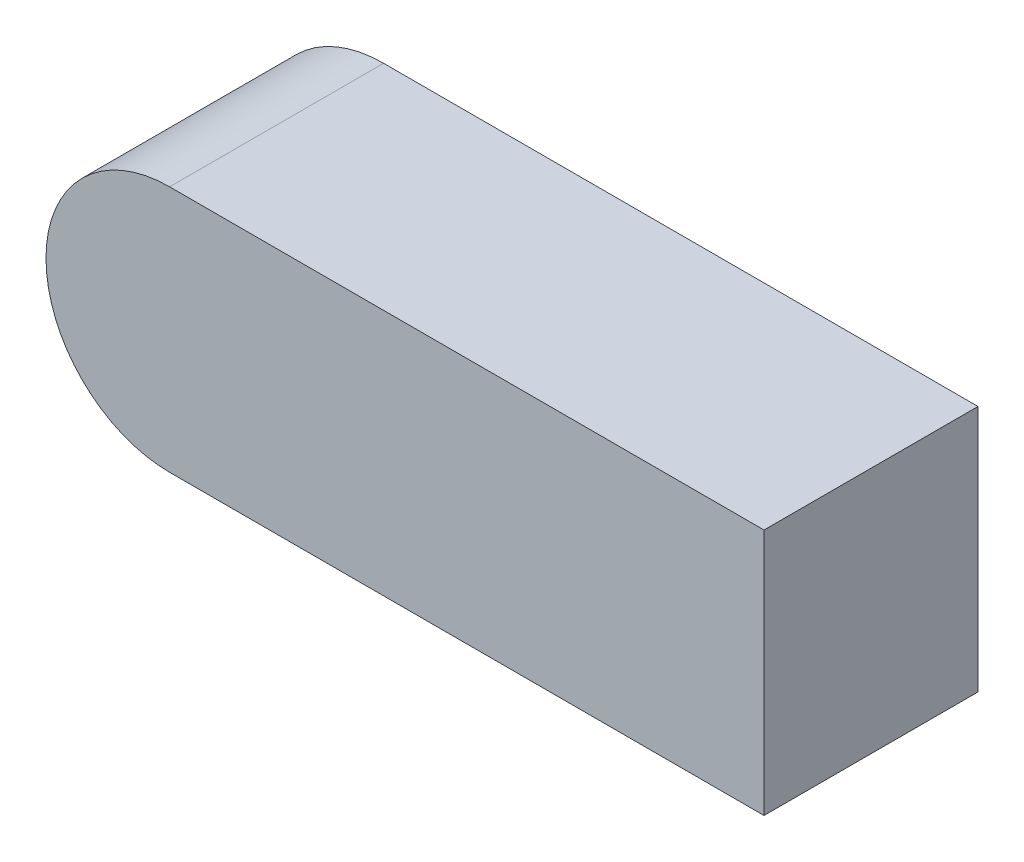
from build123d import *

# Parameters (mm, degrees)
SKETCH1_W           = 45
SKETCH1_H           = 52
BOSS_EXTRUDE1_DEPTH = 62.5
BOSS_EXTRUDE3_DEPTH = 45


with BuildPart() as part:
    # Sketch1 → Boss-Extrude1 (new body, symmetric)
    with BuildSketch(Plane(origin=(0, 0, 0), x_dir=(0, 0, -1), z_dir=(1, 0, 0))):
        Rectangle(SKETCH1_W, SKETCH1_H)
    extrude(amount=BOSS_EXTRUDE1_DEPTH, both=True)

    # Sketch3 → Boss-Extrude3 (add)
    with BuildSketch(Plane(origin=(0, 0, -22.5), x_dir=(-1, 0, 0), z_dir=(0, 0, -1))):
        with BuildLine():
            Line((62.5, -26), (62.5, 26))
            ThreePointArc((62.5, 26), (88.5, 0), (62.5, -26))
        make_face()
    extrude(amount=-BOSS_EXTRUDE3_DEPTH)


solid = part.part
